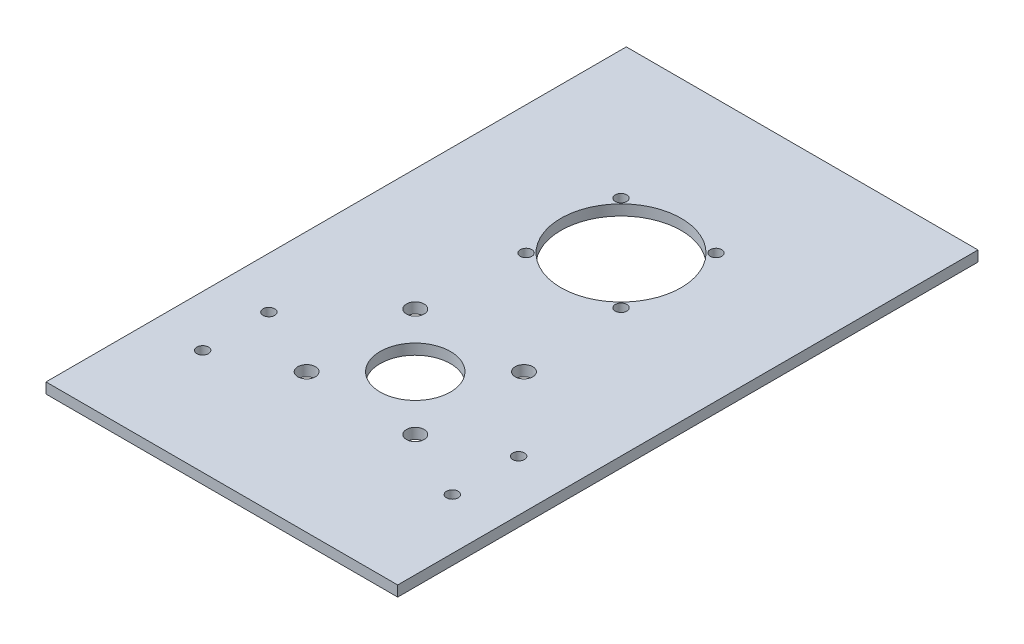
from build123d import *

# Parameters (mm, degrees)
CROQUIS1_W              = 100
CROQUIS1_H              = 165
CROQUIS1_R              = 10
CROQUIS1_R_2            = 17.1
CROQUIS1_R_3            = 2.5
CROQUIS1_R_4            = 1.65
SALIENTE_EXTRUIR1_DEPTH = 3


with BuildPart() as part:
    # Croquis1 → Saliente-Extruir1 (new body)
    with BuildSketch(Plane(origin=(0, 0, 0), x_dir=(1, 0, 0), z_dir=(0, 1, 0))):
        Rectangle(CROQUIS1_W, CROQUIS1_H)
        with Locations((0, -27.5)):
            Circle(CROQUIS1_R, mode=Mode.SUBTRACT)
        with Locations((0, 31)):
            Circle(CROQUIS1_R_2, mode=Mode.SUBTRACT)
        with Locations((-15.45, -42.95)):
            Circle(CROQUIS1_R_3, mode=Mode.SUBTRACT)
        with Locations((15.45, -42.95)):
            Circle(CROQUIS1_R_3, mode=Mode.SUBTRACT)
        with Locations((15.45, -12.05)):
            Circle(CROQUIS1_R_3, mode=Mode.SUBTRACT)
        with Locations((-15.45, -12.05)):
            Circle(CROQUIS1_R_3, mode=Mode.SUBTRACT)
        with Locations((-13.5, 17.5)):
            Circle(CROQUIS1_R_4, mode=Mode.SUBTRACT)
        with Locations((13.5, 17.5)):
            Circle(CROQUIS1_R_4, mode=Mode.SUBTRACT)
        with Locations((13.5, 44.5)):
            Circle(CROQUIS1_R_4, mode=Mode.SUBTRACT)
        with Locations((-13.5, 44.5)):
            Circle(CROQUIS1_R_4, mode=Mode.SUBTRACT)
        with Locations((35.5, -33.62222969)):
            Circle(CROQUIS1_R_4, mode=Mode.SUBTRACT)
        with Locations((35.5, -52.464842185)):
            Circle(CROQUIS1_R_4, mode=Mode.SUBTRACT)
        with Locations((-35.5, -52.464842185)):
            Circle(CROQUIS1_R_4, mode=Mode.SUBTRACT)
        with Locations((-35.5, -33.62222969)):
            Circle(CROQUIS1_R_4, mode=Mode.SUBTRACT)
    extrude(amount=SALIENTE_EXTRUIR1_DEPTH)


solid = part.part
